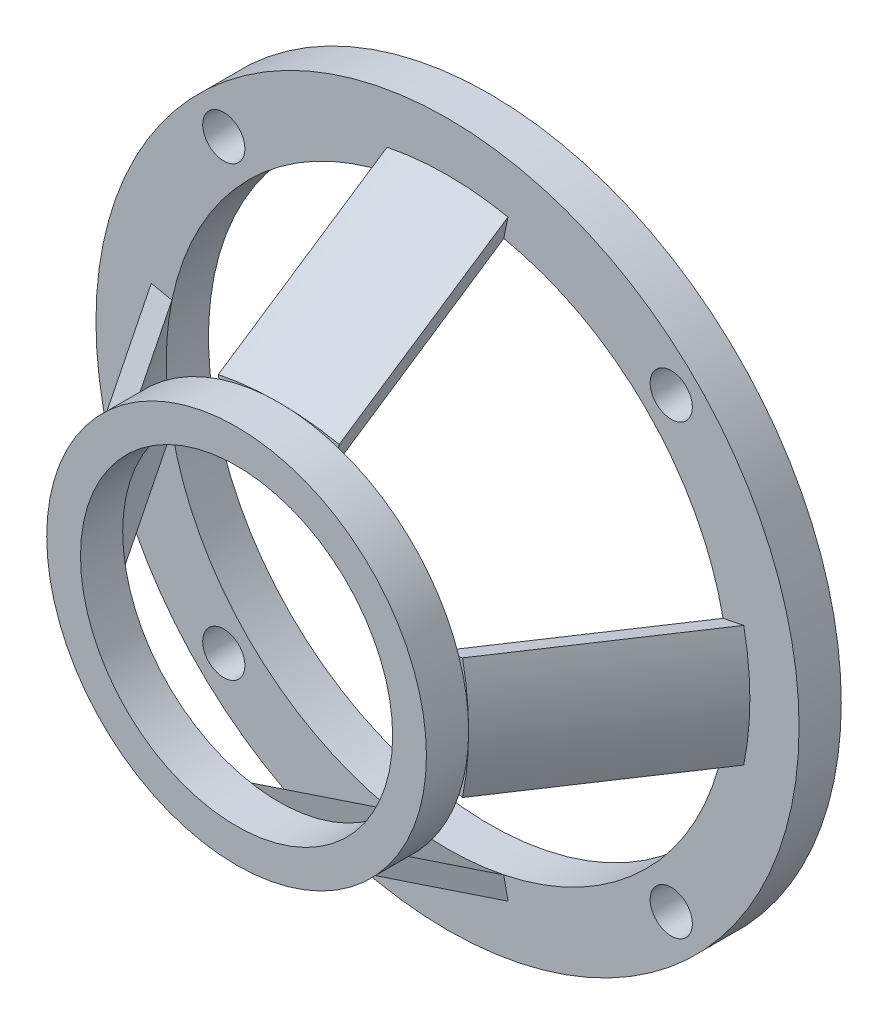
from build123d import *

# Parameters (mm, degrees)
SKETCH1_R           = 25
SKETCH1_R_2         = 20
BOSS_EXTRUDE1_DEPTH = 3
SKETCH7_R           = 13.5
SKETCH7_R_2         = 11.1
BOSS_EXTRUDE2_DEPTH = 3
CIRPATTERN2_COUNT   = 4
SKETCH3_R           = 1.5
CUT_EXTRUDE1_DEPTH  = 4
CIRPATTERN1_COUNT   = 4


with BuildPart() as part:
    # Sketch1 → Boss-Extrude1 (new body)
    with BuildSketch(Plane.XY):
        Circle(SKETCH1_R)
        Circle(SKETCH1_R_2, mode=Mode.SUBTRACT)
    extrude(amount=BOSS_EXTRUDE1_DEPTH)



with BuildPart() as body_2:
    # Sketch7 → Boss-Extrude2 (new body)
    with BuildSketch(Plane.XY.offset(15)):
        Circle(SKETCH7_R)
        Circle(SKETCH7_R_2, mode=Mode.SUBTRACT)
    extrude(amount=BOSS_EXTRUDE2_DEPTH)


with BuildPart() as part_1:
    add(part.part)

    add(body_2.part)  # Sweep1 merges body 2
    # Sweep1: sweep along a curve in space
    with BuildLine() as sweep1_path:
        Line((0, 21.5, 3), (0, 13.5, 15))
    # Sketch8 → Sweep1 (sweep)
    with BuildSketch(Plane.XY.offset(3)):
        with BuildLine():
            Line((-4.3, 21.065611788), (-4, 19.595917942))
            ThreePointArc((-4, 19.595917942), (0, 20), (4, 19.595917942))
            Line((4, 19.595917942), (4.3, 21.065611788))
            ThreePointArc((4.3, 21.065611788), (0, 21.5), (-4.3, 21.065611788))
        make_face()
    sweep1 = sweep(path=sweep1_path.line)

    # CirPattern2: Sweep1 ×4 about axis
    cirpattern2_axis = Axis((0, 0, 0), (0, 0, -1))
    for i in range(1, CIRPATTERN2_COUNT):
        add(sweep1.rotate(cirpattern2_axis, i * 360 / CIRPATTERN2_COUNT))

    # Sketch3 → Cut-Extrude1 (cut, through all)
    with BuildSketch(Plane.XY.offset(3)):
        with Locations((15.909902577, 15.909902577)):
            Circle(SKETCH3_R)
    cut_extrude1 = extrude(amount=-CUT_EXTRUDE1_DEPTH, mode=Mode.SUBTRACT)

    # CirPattern1: Cut-Extrude1 ×4 about axis
    cirpattern1_axis = Axis((0, 0, 0), (0, 0, 1))
    for i in range(1, CIRPATTERN1_COUNT):
        add(cut_extrude1.rotate(cirpattern1_axis, i * 360 / CIRPATTERN1_COUNT), mode=Mode.SUBTRACT)


solid = part_1.part
